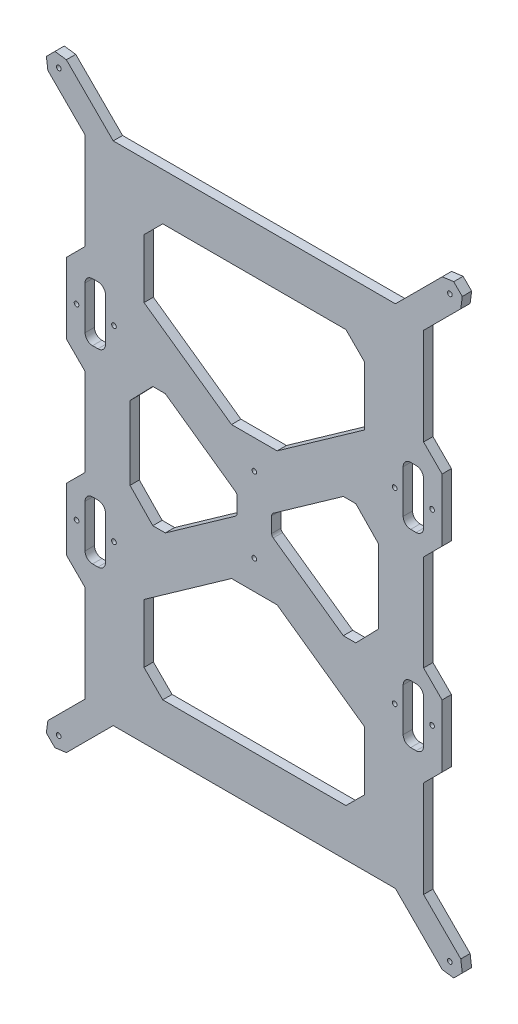
from build123d import *

# Parameters (mm, degrees)
SCHIZZO1_R                   = 1.25
ESTRUSIONE_ESTRUSIONE1_DEPTH = 5


with BuildPart() as part:
    # Schizzo1 → Estrusione-Estrusione1 (new body)
    with BuildSketch(Plane.XY):
        Polygon((-111.130864092, 156.55753287), (-106.55753287, 161.130864092), (-100.431262317, 160.330757253), (-75.393295673, 135.29279061), (75.393295673, 135.29279061), (100.431262317, 160.330757253), (106.55753287, 161.130864092), (111.130864092, 156.55753287), (110.330757253, 150.431262317), (90.448609444, 130.549114507), (90.448609444, 78.874114811), (100.330757253, 68.991967001), (100.330757253, 35.563826068), (90.448609444, 25.681678258), (90.448609444, -25.681678258), (100.330757253, -35.563826068), (100.330757253, -68.991967001), (90.448609444, -78.874114811), (90.448609444, -130.549114507), (110.330757253, -150.431262317), (111.130864092, -156.55753287), (106.55753287, -161.130864092), (100.431262317, -160.330757253), (75.393295673, -135.29279061), (-75.393295673, -135.29279061), (-100.431262317, -160.330757253), (-106.55753287, -161.130864092), (-111.130864092, -156.55753287), (-110.330757253, -150.431262317), (-90.448609444, -130.549114507), (-90.448609444, -78.874114811), (-100.330757253, -68.991967001), (-100.330757253, -35.563826068), (-90.448609444, -25.681678258), (-90.448609444, 21.125885189), (-100.330757253, 31.008032999), (-100.330757253, 68.991967001), (-90.448609444, 78.874114811), (-90.448609444, 130.549114507), (-110.330757253, 150.431262317), align=None)
        with Locations((-95, 50)):
            Circle(SCHIZZO1_R, mode=Mode.SUBTRACT)
        with Locations((-75, 50)):
            Circle(SCHIZZO1_R, mode=Mode.SUBTRACT)
        with Locations((-104.5, 154.5)):
            Circle(SCHIZZO1_R, mode=Mode.SUBTRACT)
        with Locations((104.5, 154.5)):
            Circle(SCHIZZO1_R, mode=Mode.SUBTRACT)
        with Locations((75, 50)):
            Circle(SCHIZZO1_R, mode=Mode.SUBTRACT)
        with Locations((95, 50)):
            Circle(SCHIZZO1_R, mode=Mode.SUBTRACT)
        with Locations((0, 20.131279802)):
            Circle(SCHIZZO1_R, mode=Mode.SUBTRACT)
        with Locations((0, -20.131279802)):
            Circle(SCHIZZO1_R, mode=Mode.SUBTRACT)
        with Locations((95, -50)):
            Circle(SCHIZZO1_R, mode=Mode.SUBTRACT)
        with Locations((75, -50)):
            Circle(SCHIZZO1_R, mode=Mode.SUBTRACT)
        with Locations((104.5, -154.5)):
            Circle(SCHIZZO1_R, mode=Mode.SUBTRACT)
        with Locations((-104.5, -154.5)):
            Circle(SCHIZZO1_R, mode=Mode.SUBTRACT)
        with Locations((-75, -50)):
            Circle(SCHIZZO1_R, mode=Mode.SUBTRACT)
        with Locations((-95, -50)):
            Circle(SCHIZZO1_R, mode=Mode.SUBTRACT)
        with BuildLine():
            Line((-66.435665908, 19.62934529), (-66.435665908, -19.62934529))
            Line((-66.435665908, -19.62934529), (-54.243131725, -32.22180516))
            Line((-54.243131725, -32.22180516), (-47.563810674, -32.22180516))
            Line((-47.563810674, -32.22180516), (-10.101900389, -5.729003291))
            ThreePointArc((-10.101900389, -5.729003291), (-9.48052072, -5.015427148), (-9.256694819, -4.096076524))
            Line((-9.256694819, -4.096076524), (-9.256694819, 4.096076524))
            ThreePointArc((-9.256694819, 4.096076524), (-9.48052072, 5.015427148), (-10.101900389, 5.729003291))
            Line((-10.101900389, 5.729003291), (-47.563810674, 32.22180516))
            Line((-47.563810674, 32.22180516), (-54.243131725, 32.22180516))
            Line((-54.243131725, 32.22180516), (-66.435665908, 19.62934529))
        make_face(mode=Mode.SUBTRACT)
        Polygon((-58.942185062, 100.139969228), (-58.942185062, 68.700211283), (-12.181822312, 35.631608635), (12.181822312, 35.631608635), (58.942185062, 68.700211283), (58.942185062, 100.139969228), (48.942185062, 110.139969228), (-48.942185062, 110.139969228), align=None, mode=Mode.SUBTRACT)
        with BuildLine():
            Line((-86.448609444, 35.007036896), (-83.551390556, 35.007036896))
            ThreePointArc((-83.551390556, 35.007036896), (-80.722963432, 36.178609771), (-79.551390556, 39.007036896))
            Line((-79.551390556, 39.007036896), (-79.551390556, 62.007036896))
            ThreePointArc((-79.551390556, 62.007036896), (-80.722963432, 64.835464021), (-83.551390556, 66.007036896))
            Line((-83.551390556, 66.007036896), (-86.448609444, 66.007036896))
            ThreePointArc((-86.448609444, 66.007036896), (-89.277036568, 64.835464021), (-90.448609444, 62.007036896))
            Line((-90.448609444, 62.007036896), (-90.448609444, 39.007036896))
            ThreePointArc((-90.448609444, 39.007036896), (-89.277036568, 36.178609771), (-86.448609444, 35.007036896))
        make_face(mode=Mode.SUBTRACT)
        with BuildLine():
            Line((86.448609444, 66.007036896), (83.551390556, 66.007036896))
            ThreePointArc((83.551390556, 66.007036896), (80.722963432, 64.835464021), (79.551390556, 62.007036896))
            Line((79.551390556, 62.007036896), (79.551390556, 39.007036896))
            ThreePointArc((79.551390556, 39.007036896), (80.722963432, 36.178609771), (83.551390556, 35.007036896))
            Line((83.551390556, 35.007036896), (86.448609444, 35.007036896))
            ThreePointArc((86.448609444, 35.007036896), (89.277036568, 36.178609771), (90.448609444, 39.007036896))
            Line((90.448609444, 39.007036896), (90.448609444, 62.007036896))
            ThreePointArc((90.448609444, 62.007036896), (89.277036568, 64.835464021), (86.448609444, 66.007036896))
        make_face(mode=Mode.SUBTRACT)
        with BuildLine():
            Line((47.563810674, 32.22180516), (10.101900389, 5.729003291))
            ThreePointArc((10.101900389, 5.729003291), (9.48052072, 5.015427148), (9.256694819, 4.096076524))
            Line((9.256694819, 4.096076524), (9.256694819, -4.096076524))
            ThreePointArc((9.256694819, -4.096076524), (9.48052072, -5.015427148), (10.101900389, -5.729003291))
            Line((10.101900389, -5.729003291), (47.563810674, -32.22180516))
            Line((47.563810674, -32.22180516), (54.243131725, -32.22180516))
            Line((54.243131725, -32.22180516), (66.435665908, -19.62934529))
            Line((66.435665908, -19.62934529), (66.435665908, 19.62934529))
            Line((66.435665908, 19.62934529), (54.243131725, 32.22180516))
            Line((54.243131725, 32.22180516), (47.563810674, 32.22180516))
        make_face(mode=Mode.SUBTRACT)
        with BuildLine():
            Line((-86.448609444, -66.007036896), (-83.551390556, -66.007036896))
            ThreePointArc((-83.551390556, -66.007036896), (-80.722963432, -64.835464021), (-79.551390556, -62.007036896))
            Line((-79.551390556, -62.007036896), (-79.551390556, -39.007036896))
            ThreePointArc((-79.551390556, -39.007036896), (-80.722963432, -36.178609771), (-83.551390556, -35.007036896))
            Line((-83.551390556, -35.007036896), (-86.448609444, -35.007036896))
            ThreePointArc((-86.448609444, -35.007036896), (-89.277036568, -36.178609771), (-90.448609444, -39.007036896))
            Line((-90.448609444, -39.007036896), (-90.448609444, -62.007036896))
            ThreePointArc((-90.448609444, -62.007036896), (-89.277036568, -64.835464021), (-86.448609444, -66.007036896))
        make_face(mode=Mode.SUBTRACT)
        Polygon((-48.942185062, -110.139969228), (48.942185062, -110.139969228), (58.942185062, -100.139969228), (58.942185062, -68.700211283), (12.181822312, -35.631608635), (-12.181822312, -35.631608635), (-58.942185062, -68.700211283), (-58.942185062, -100.139969228), align=None, mode=Mode.SUBTRACT)
        with BuildLine():
            Line((86.448609444, -35.007036896), (83.551390556, -35.007036896))
            ThreePointArc((83.551390556, -35.007036896), (80.722963432, -36.178609771), (79.551390556, -39.007036896))
            Line((79.551390556, -39.007036896), (79.551390556, -62.007036896))
            ThreePointArc((79.551390556, -62.007036896), (80.722963432, -64.835464021), (83.551390556, -66.007036896))
            Line((83.551390556, -66.007036896), (86.448609444, -66.007036896))
            ThreePointArc((86.448609444, -66.007036896), (89.277036568, -64.835464021), (90.448609444, -62.007036896))
            Line((90.448609444, -62.007036896), (90.448609444, -39.007036896))
            ThreePointArc((90.448609444, -39.007036896), (89.277036568, -36.178609771), (86.448609444, -35.007036896))
        make_face(mode=Mode.SUBTRACT)
    extrude(amount=-ESTRUSIONE_ESTRUSIONE1_DEPTH)


solid = part.part
